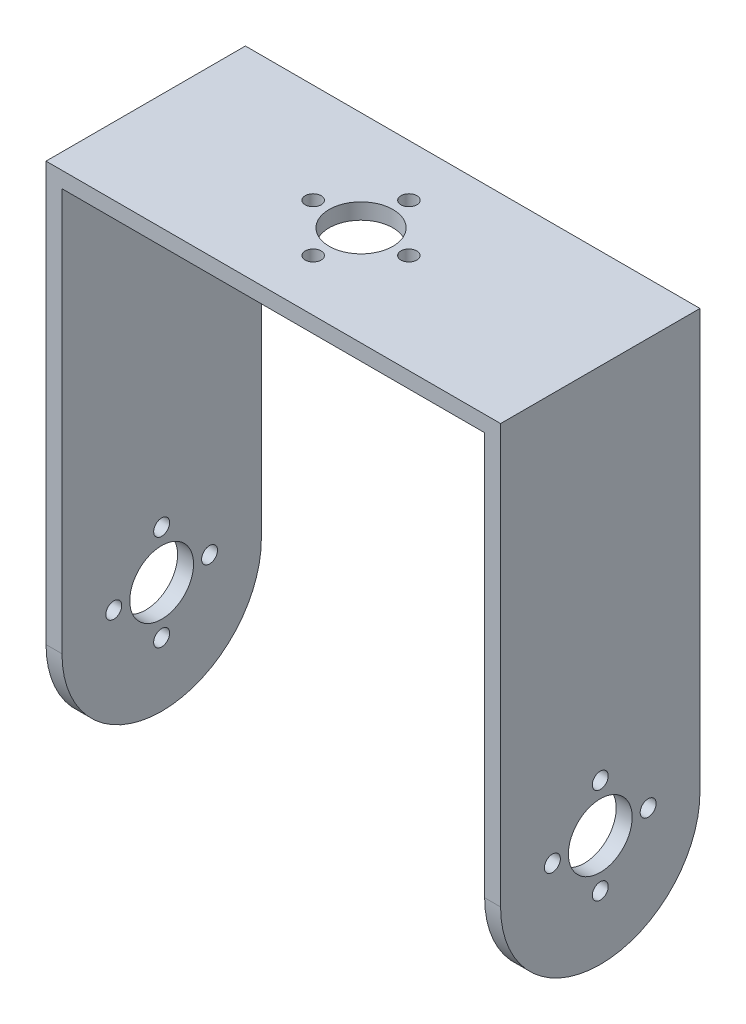
from build123d import *

# Parameters (mm, degrees)
BOSS_EXTRUDE2_DEPTH = 25
SKETCH4_R           = 4
CUT_EXTRUDE1_DEPTH  = 66
SKETCH6_R           = 4
CUT_EXTRUDE2_DEPTH  = 58
CUT_EXTRUDE3_DEPTH  = 58
SKETCH9_R           = 1
CUT_EXTRUDE4_DEPTH  = 58
SKETCH10_R          = 1
CUT_EXTRUDE5_DEPTH  = 66


with BuildPart() as part:
    # Sketch3 → Boss-Extrude2 (new body)
    with BuildSketch(Plane.XY):
        Polygon((-79.925523148, 45.386502584), (-27.042967192, 45.386502584), (-24.925523148, 45.386502584), (-24.925523148, -19.613497416), (-26.925523148, -19.613497416), (-26.925523148, 43.389953837), (-79.925523148, 43.389953837), (-79.925523148, -19.613497416), (-81.925523148, -19.613497416), (-81.925523148, 45.386502584), align=None)
    extrude(amount=BOSS_EXTRUDE2_DEPTH)

    # Sketch4 → Cut-Extrude1 (cut, through all)
    with BuildSketch(Plane(origin=(0, 45.386502584, 0), x_dir=(1, 0, 0), z_dir=(0, 1, 0))):
        with Locations((-54.925523148, -12.5)):
            Circle(SKETCH4_R)
    extrude(amount=-CUT_EXTRUDE1_DEPTH, mode=Mode.SUBTRACT)

    # Sketch6 → Cut-Extrude2 (cut, through all)
    with BuildSketch(Plane.ZY.offset(81.925523148)):
        with Locations((12.5, -5.613497416)):
            Circle(SKETCH6_R)
    extrude(amount=-CUT_EXTRUDE2_DEPTH, mode=Mode.SUBTRACT)

    # Sketch8 → Cut-Extrude3 (cut, through all)
    with BuildSketch(Plane.ZY.offset(81.925523148)):
        with BuildLine():
            Line((0, -19.613497416), (12.5, -19.613497416))
            ThreePointArc((12.5, -19.613497416), (3.661165213, -15.952332159), (0, -7.113497352))
            Line((0, -7.113497352), (0, -19.613497416))
        make_face()
        with BuildLine():
            Line((12.5, -19.613497416), (25, -19.613497416))
            Line((25, -19.613497416), (25, -7.113497416))
            ThreePointArc((25, -7.113497416), (21.338834765, -15.952332181), (12.5, -19.613497416))
        make_face()
    extrude(amount=-CUT_EXTRUDE3_DEPTH, mode=Mode.SUBTRACT)

    # Sketch9 → Cut-Extrude4 (cut, through all)
    with BuildSketch(Plane(origin=(-24.925523148, 0, 0), x_dir=(0, 0, -1), z_dir=(1, 0, 0))):
        with Locations((-12.5, -11.6185898)):
            Circle(SKETCH9_R)
        with Locations((-18.505092383, -5.613497416)):
            Circle(SKETCH9_R)
        with Locations((-6.494907617, -5.613497416)):
            Circle(SKETCH9_R)
        with Locations((-12.5, 0.391594967)):
            Circle(SKETCH9_R)
    extrude(amount=-CUT_EXTRUDE4_DEPTH, mode=Mode.SUBTRACT)

    # Sketch10 → Cut-Extrude5 (cut, through all)
    with BuildSketch(Plane(origin=(0, 45.386502584, 0), x_dir=(1, 0, 0), z_dir=(0, 1, 0))):
        with Locations((-48.925524223, -12.499998866)):
            Circle(SKETCH10_R)
        with Locations((-54.925524223, -6.499998866)):
            Circle(SKETCH10_R)
        with Locations((-54.925524223, -18.499998866)):
            Circle(SKETCH10_R)
        with Locations((-60.925524223, -12.499998866)):
            Circle(SKETCH10_R)
    extrude(amount=-CUT_EXTRUDE5_DEPTH, mode=Mode.SUBTRACT)


solid = part.part
